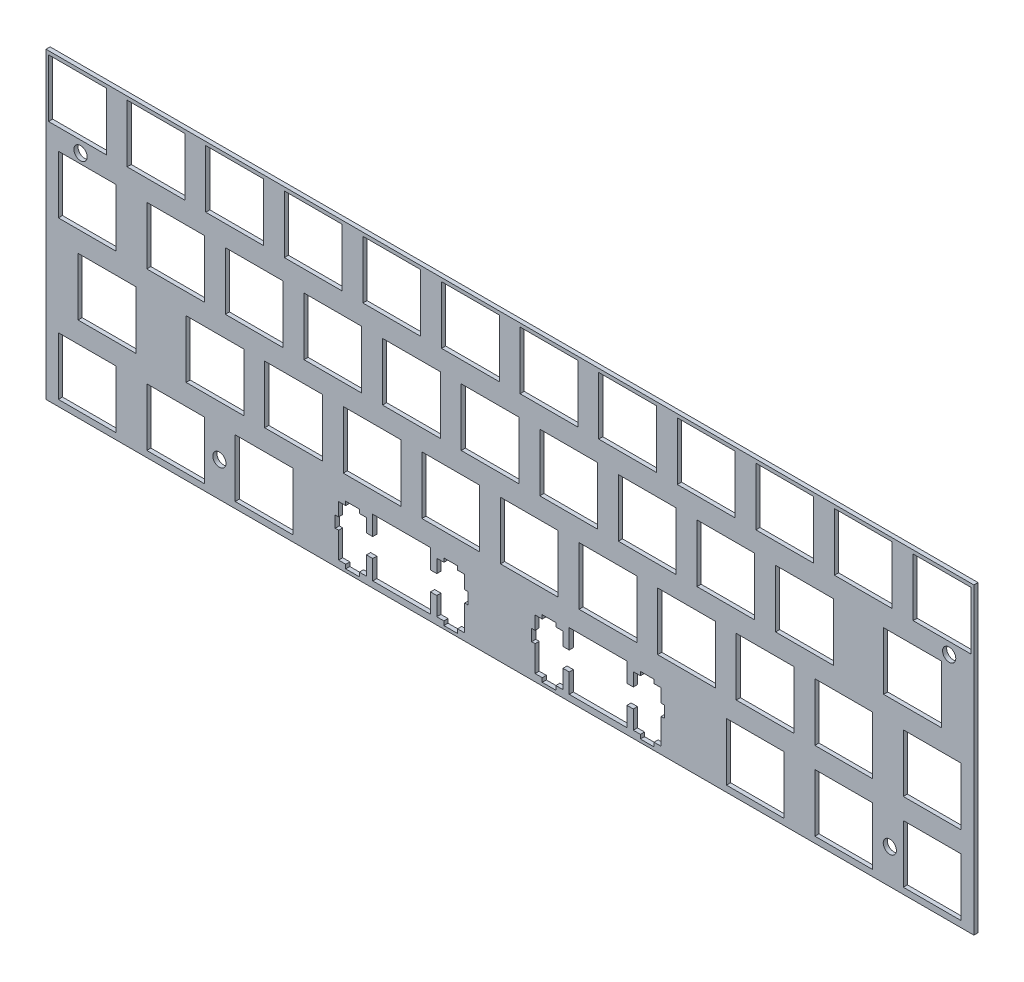
from build123d import *

# Parameters (mm, degrees)
MODEL_W         = 224.901447803
MODEL_H         = 73.517145034
MODEL_R         = 1.6
MODEL_W_2       = 13.99949
MODEL_H_2       = 13.99946
MODEL_W_3       = 13.9993
MODEL_W_4       = 14.0007
MODEL_W_5       = 13.999
MODEL_W_6       = 14
MODEL_W_7       = 14.001
MODEL_W_8       = 14.00087
MODEL_H_3       = 13.9994
MODEL_W_9       = 13.9998
MODEL_H_4       = 13.9993
MODEL_W_10      = 13.99955
EXTRUDE_1_DEPTH = 1


with BuildPart() as part:
    # Model → 凸台-拉伸1 (new body)
    with BuildSketch(Plane.XY):
        with Locations((114.453866517, 38.034360499)):
            Rectangle(MODEL_W, MODEL_H)
        with Locations((10.376158361, 57.165898762)):
            Circle(MODEL_R, mode=Mode.SUBTRACT)
        with Locations((44.031225671, 9.648803728)):
            Circle(MODEL_R, mode=Mode.SUBTRACT)
        with Locations((206.531550672, 9.648803728)):
            Circle(MODEL_R, mode=Mode.SUBTRACT)
        with Locations((220.917578224, 57.165898762)):
            Circle(MODEL_R, mode=Mode.SUBTRACT)
        Polygon((81.201, 16.7831), (81.201, 12.0826), (79.6756, 12.0826), (79.6756, 15.3128), (77.9501, 15.3128), (77.9501, 16.2347), (74.651, 16.2347), (74.651, 15.3128), (72.9259, 15.3128), (72.9259, 12.0826), (72.1004, 12.0826), (72.1004, 9.28384), (72.9259, 9.28384), (72.9259, 3.01377), (74.651, 3.01377), (74.651, 2.03261), (77.9501, 2.03261), (77.9501, 3.01377), (79.6756, 3.01377), (79.6756, 7.48273), (81.201, 7.48273), (81.201, 2.78364), (95.2003, 2.78364), (95.2003, 7.48273), (96.726, 7.48273), (96.726, 3.01377), (98.4497, 3.01377), (98.4497, 2.03261), (101.75, 2.03261), (101.75, 3.01377), (103.475, 3.01377), (103.475, 9.28384), (104.301, 9.28384), (104.301, 12.0826), (103.475, 12.0826), (103.475, 15.3128), (101.75, 15.3128), (101.75, 16.2347), (98.4497, 16.2347), (98.4497, 15.3128), (96.726, 15.3128), (96.726, 12.0826), (95.2003, 12.0826), (95.2003, 16.7831), align=None, mode=Mode.SUBTRACT)
        Polygon((128.826, 16.7831), (128.826, 12.0826), (127.301, 12.0826), (127.301, 15.3128), (125.575, 15.3128), (125.575, 16.2347), (122.276, 16.2347), (122.276, 15.3128), (120.551, 15.3128), (120.551, 12.0826), (119.725, 12.0826), (119.725, 9.28384), (120.551, 9.28384), (120.551, 3.01377), (122.276, 3.01377), (122.276, 2.03261), (125.575, 2.03261), (125.575, 3.01377), (127.301, 3.01377), (127.301, 7.48273), (128.826, 7.48273), (128.826, 2.78364), (142.825, 2.78364), (142.825, 7.48273), (144.351, 7.48273), (144.351, 3.01377), (146.076, 3.01377), (146.076, 2.03261), (149.375, 2.03261), (149.375, 3.01377), (151.1, 3.01377), (151.1, 9.28384), (151.926, 9.28384), (151.926, 12.0826), (151.1, 12.0826), (151.1, 15.3128), (149.375, 15.3128), (149.375, 16.2347), (146.076, 16.2347), (146.076, 15.3128), (144.351, 15.3128), (144.351, 12.0826), (142.825, 12.0826), (142.825, 16.7831), align=None, mode=Mode.SUBTRACT)
        with Locations((12.000655, 9.78337)):
            Rectangle(MODEL_W_2, MODEL_H_2, mode=Mode.SUBTRACT)
        with Locations((33.43185, 9.78337)):
            Rectangle(MODEL_W_3, MODEL_H_2, mode=Mode.SUBTRACT)
        with Locations((54.86245, 9.78337)):
            Rectangle(MODEL_W_4, MODEL_H_2, mode=Mode.SUBTRACT)
        with Locations((173.9255, 9.78337)):
            Rectangle(MODEL_W_5, MODEL_H_2, mode=Mode.SUBTRACT)
        with Locations((195.357, 9.78337)):
            Rectangle(MODEL_W_6, MODEL_H_2, mode=Mode.SUBTRACT)
        with Locations((216.7875, 9.78337)):
            Rectangle(MODEL_W_7, MODEL_H_2, mode=Mode.SUBTRACT)
        with Locations((16.762465, 28.8333)):
            Rectangle(MODEL_W_8, MODEL_H_3, mode=Mode.SUBTRACT)
        with Locations((42.95685, 28.8333)):
            Rectangle(MODEL_W_3, MODEL_H_3, mode=Mode.SUBTRACT)
        with Locations((62.00685, 28.8333)):
            Rectangle(MODEL_W_3, MODEL_H_3, mode=Mode.SUBTRACT)
        with Locations((81.05685, 28.8333)):
            Rectangle(MODEL_W_3, MODEL_H_3, mode=Mode.SUBTRACT)
        with Locations((100.1071, 28.8333)):
            Rectangle(MODEL_W_9, MODEL_H_3, mode=Mode.SUBTRACT)
        with Locations((119.157, 28.8333)):
            Rectangle(MODEL_W_6, MODEL_H_3, mode=Mode.SUBTRACT)
        with Locations((138.207, 28.8333)):
            Rectangle(MODEL_W_6, MODEL_H_3, mode=Mode.SUBTRACT)
        with Locations((157.257, 28.8333)):
            Rectangle(MODEL_W_6, MODEL_H_3, mode=Mode.SUBTRACT)
        with Locations((176.307, 28.8333)):
            Rectangle(MODEL_W_6, MODEL_H_3, mode=Mode.SUBTRACT)
        with Locations((195.357, 28.8333)):
            Rectangle(MODEL_W_6, MODEL_H_3, mode=Mode.SUBTRACT)
        with Locations((216.7875, 28.8333)):
            Rectangle(MODEL_W_7, MODEL_H_3, mode=Mode.SUBTRACT)
        with Locations((12.000655, 47.88345)):
            Rectangle(MODEL_W_2, MODEL_H_4, mode=Mode.SUBTRACT)
        with Locations((33.43185, 47.88345)):
            Rectangle(MODEL_W_3, MODEL_H_4, mode=Mode.SUBTRACT)
        with Locations((52.48185, 47.88345)):
            Rectangle(MODEL_W_3, MODEL_H_4, mode=Mode.SUBTRACT)
        with Locations((71.53185, 47.88345)):
            Rectangle(MODEL_W_3, MODEL_H_4, mode=Mode.SUBTRACT)
        with Locations((90.58185, 47.88345)):
            Rectangle(MODEL_W_3, MODEL_H_4, mode=Mode.SUBTRACT)
        with Locations((109.632, 47.88345)):
            Rectangle(MODEL_W_6, MODEL_H_4, mode=Mode.SUBTRACT)
        with Locations((128.682, 47.88345)):
            Rectangle(MODEL_W_6, MODEL_H_4, mode=Mode.SUBTRACT)
        with Locations((147.732, 47.88345)):
            Rectangle(MODEL_W_6, MODEL_H_4, mode=Mode.SUBTRACT)
        with Locations((166.782, 47.88345)):
            Rectangle(MODEL_W_6, MODEL_H_4, mode=Mode.SUBTRACT)
        with Locations((185.832, 47.88345)):
            Rectangle(MODEL_W_6, MODEL_H_4, mode=Mode.SUBTRACT)
        with Locations((212.0255, 47.88345)):
            Rectangle(MODEL_W_5, MODEL_H_4, mode=Mode.SUBTRACT)
        with Locations((9.619425, 66.93345)):
            Rectangle(MODEL_W_10, MODEL_H_4, mode=Mode.SUBTRACT)
        with Locations((28.66935, 66.93345)):
            Rectangle(MODEL_W_3, MODEL_H_4, mode=Mode.SUBTRACT)
        with Locations((47.71935, 66.93345)):
            Rectangle(MODEL_W_3, MODEL_H_4, mode=Mode.SUBTRACT)
        with Locations((66.76935, 66.93345)):
            Rectangle(MODEL_W_3, MODEL_H_4, mode=Mode.SUBTRACT)
        with Locations((85.81935, 66.93345)):
            Rectangle(MODEL_W_3, MODEL_H_4, mode=Mode.SUBTRACT)
        with Locations((104.86865, 66.93345)):
            Rectangle(MODEL_W_4, MODEL_H_4, mode=Mode.SUBTRACT)
        with Locations((123.9185, 66.93345)):
            Rectangle(MODEL_W_7, MODEL_H_4, mode=Mode.SUBTRACT)
        with Locations((142.9695, 66.93345)):
            Rectangle(MODEL_W_5, MODEL_H_4, mode=Mode.SUBTRACT)
        with Locations((162.0195, 66.93345)):
            Rectangle(MODEL_W_5, MODEL_H_4, mode=Mode.SUBTRACT)
        with Locations((181.0695, 66.93345)):
            Rectangle(MODEL_W_5, MODEL_H_4, mode=Mode.SUBTRACT)
        with Locations((200.1195, 66.93345)):
            Rectangle(MODEL_W_5, MODEL_H_4, mode=Mode.SUBTRACT)
        with Locations((219.1695, 66.93345)):
            Rectangle(MODEL_W_5, MODEL_H_4, mode=Mode.SUBTRACT)
    extrude(amount=EXTRUDE_1_DEPTH)


solid = part.part
